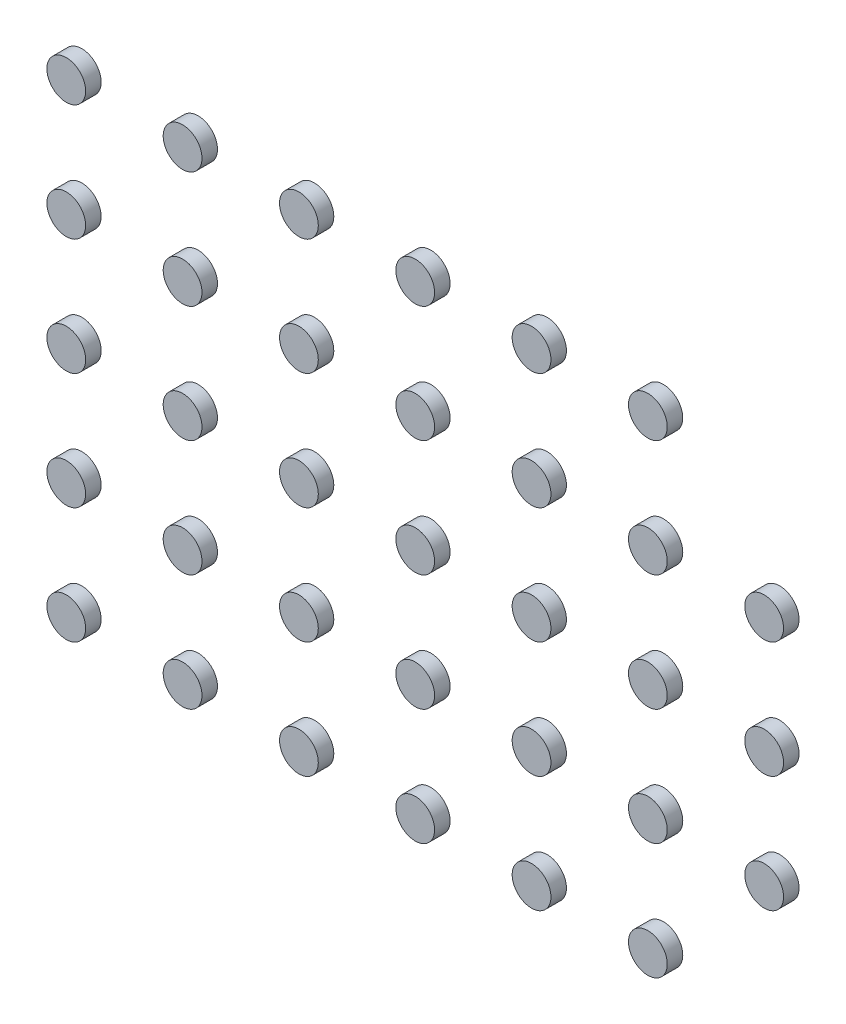
from build123d import *

# Parameters (mm, degrees)
SKETCH_1_R         = 0.5
EXTRUDE_1_DEPTH    = 0.4
EXTRUDE_1_2_DEPTH  = 0.4
EXTRUDE_1_3_DEPTH  = 0.4
EXTRUDE_1_4_DEPTH  = 0.4
EXTRUDE_1_5_DEPTH  = 0.4
EXTRUDE_1_6_DEPTH  = 0.4
EXTRUDE_1_7_DEPTH  = 0.4
EXTRUDE_1_8_DEPTH  = 0.4
EXTRUDE_1_9_DEPTH  = 0.4
EXTRUDE_1_10_DEPTH = 0.4
EXTRUDE_1_11_DEPTH = 0.4
EXTRUDE_1_12_DEPTH = 0.4
EXTRUDE_1_13_DEPTH = 0.4
EXTRUDE_1_14_DEPTH = 0.4
EXTRUDE_1_15_DEPTH = 0.4
EXTRUDE_1_16_DEPTH = 0.4
EXTRUDE_1_17_DEPTH = 0.4
EXTRUDE_1_18_DEPTH = 0.4
EXTRUDE_1_19_DEPTH = 0.4
EXTRUDE_1_20_DEPTH = 0.4
EXTRUDE_1_21_DEPTH = 0.4
EXTRUDE_1_22_DEPTH = 0.4
EXTRUDE_1_23_DEPTH = 0.4
EXTRUDE_1_24_DEPTH = 0.4
EXTRUDE_1_25_DEPTH = 0.4
EXTRUDE_1_26_DEPTH = 0.4
EXTRUDE_1_27_DEPTH = 0.4
EXTRUDE_1_28_DEPTH = 0.4
EXTRUDE_1_29_DEPTH = 0.4
EXTRUDE_1_30_DEPTH = 0.4
EXTRUDE_1_31_DEPTH = 0.4
EXTRUDE_1_32_DEPTH = 0.4
EXTRUDE_1_33_DEPTH = 0.4
EXTRUDE_1_34_DEPTH = 0.4
EXTRUDE_1_35_DEPTH = 0.4
EXTRUDE_1_36_DEPTH = 0.4
EXTRUDE_1_37_DEPTH = 0.4
EXTRUDE_1_38_DEPTH = 0.4
EXTRUDE_1_39_DEPTH = 0.4
EXTRUDE_1_40_DEPTH = 0.4
EXTRUDE_1_41_DEPTH = 0.4
EXTRUDE_1_42_DEPTH = 0.4


with BuildPart() as part:
    # 草图1 → 凸台-拉伸1 (new body)
    with BuildSketch(Plane.XY):
        with Locations((-4.5, 1.5)):
            Circle(SKETCH_1_R)
    extrude(amount=EXTRUDE_1_DEPTH)


with BuildPart() as body_2:
    # 草图1 → Extrude 1 2 (new body)
    with BuildSketch(Plane.XY):
        with Locations((-1.5, 1.5)):
            Circle(SKETCH_1_R)
    extrude(amount=EXTRUDE_1_2_DEPTH)


with BuildPart() as body_3:
    # 草图1 → Extrude 1 3 (new body)
    with BuildSketch(Plane.XY):
        with Locations((1.5, 1.5)):
            Circle(SKETCH_1_R)
    extrude(amount=EXTRUDE_1_3_DEPTH)


with BuildPart() as body_4:
    # 草图1 → Extrude 1 4 (new body)
    with BuildSketch(Plane.XY):
        with Locations((4.5, 1.5)):
            Circle(SKETCH_1_R)
    extrude(amount=EXTRUDE_1_4_DEPTH)


with BuildPart() as body_5:
    # 草图1 → Extrude 1 5 (new body)
    with BuildSketch(Plane.XY):
        with Locations((7.5, 1.5)):
            Circle(SKETCH_1_R)
    extrude(amount=EXTRUDE_1_5_DEPTH)


with BuildPart() as body_6:
    # 草图1 → Extrude 1 6 (new body)
    with BuildSketch(Plane.XY):
        with Locations((10.5, 1.5)):
            Circle(SKETCH_1_R)
    extrude(amount=EXTRUDE_1_6_DEPTH)


with BuildPart() as body_7:
    # 草图1 → Extrude 1 7 (new body)
    with BuildSketch(Plane.XY):
        with Locations((10.5, -1.5)):
            Circle(SKETCH_1_R)
    extrude(amount=EXTRUDE_1_7_DEPTH)


with BuildPart() as body_8:
    # 草图1 → Extrude 1 8 (new body)
    with BuildSketch(Plane.XY):
        with Locations((7.5, -1.5)):
            Circle(SKETCH_1_R)
    extrude(amount=EXTRUDE_1_8_DEPTH)


with BuildPart() as body_9:
    # 草图1 → Extrude 1 9 (new body)
    with BuildSketch(Plane.XY):
        with Locations((-10.5, 7.5)):
            Circle(SKETCH_1_R)
    extrude(amount=EXTRUDE_1_9_DEPTH)


with BuildPart() as body_10:
    # 草图1 → Extrude 1 10 (new body)
    with BuildSketch(Plane.XY):
        with Locations((-1.5, 7.5)):
            Circle(SKETCH_1_R)
    extrude(amount=EXTRUDE_1_10_DEPTH)


with BuildPart() as body_11:
    # 草图1 → Extrude 1 11 (new body)
    with BuildSketch(Plane.XY):
        with Locations((1.5, 7.5)):
            Circle(SKETCH_1_R)
    extrude(amount=EXTRUDE_1_11_DEPTH)


with BuildPart() as body_12:
    # 草图1 → Extrude 1 12 (new body)
    with BuildSketch(Plane.XY):
        with Locations((4.5, 7.5)):
            Circle(SKETCH_1_R)
    extrude(amount=EXTRUDE_1_12_DEPTH)


with BuildPart() as body_13:
    # 草图1 → Extrude 1 13 (new body)
    with BuildSketch(Plane.XY):
        with Locations((-10.5, 1.5)):
            Circle(SKETCH_1_R)
    extrude(amount=EXTRUDE_1_13_DEPTH)


with BuildPart() as body_14:
    # 草图1 → Extrude 1 14 (new body)
    with BuildSketch(Plane.XY):
        with Locations((-10.5, 4.5)):
            Circle(SKETCH_1_R)
    extrude(amount=EXTRUDE_1_14_DEPTH)


with BuildPart() as body_15:
    # 草图1 → Extrude 1 15 (new body)
    with BuildSketch(Plane.XY):
        with Locations((-10.5, -1.5)):
            Circle(SKETCH_1_R)
    extrude(amount=EXTRUDE_1_15_DEPTH)


with BuildPart() as body_16:
    # 草图1 → Extrude 1 16 (new body)
    with BuildSketch(Plane.XY):
        with Locations((-10.5, -4.5)):
            Circle(SKETCH_1_R)
    extrude(amount=EXTRUDE_1_16_DEPTH)


with BuildPart() as body_17:
    # 草图1 → Extrude 1 17 (new body)
    with BuildSketch(Plane.XY):
        with Locations((-10.5, -7.5)):
            Circle(SKETCH_1_R)
    extrude(amount=EXTRUDE_1_17_DEPTH)


with BuildPart() as body_18:
    # 草图1 → Extrude 1 18 (new body)
    with BuildSketch(Plane.XY):
        with Locations((-7.5, -7.5)):
            Circle(SKETCH_1_R)
    extrude(amount=EXTRUDE_1_18_DEPTH)


with BuildPart() as body_19:
    # 草图1 → Extrude 1 19 (new body)
    with BuildSketch(Plane.XY):
        with Locations((-7.5, -4.5)):
            Circle(SKETCH_1_R)
    extrude(amount=EXTRUDE_1_19_DEPTH)


with BuildPart() as body_20:
    # 草图1 → Extrude 1 20 (new body)
    with BuildSketch(Plane.XY):
        with Locations((-7.5, -1.5)):
            Circle(SKETCH_1_R)
    extrude(amount=EXTRUDE_1_20_DEPTH)


with BuildPart() as body_21:
    # 草图1 → Extrude 1 21 (new body)
    with BuildSketch(Plane.XY):
        with Locations((-7.5, 1.5)):
            Circle(SKETCH_1_R)
    extrude(amount=EXTRUDE_1_21_DEPTH)


with BuildPart() as body_22:
    # 草图1 → Extrude 1 22 (new body)
    with BuildSketch(Plane.XY):
        with Locations((-7.5, 4.5)):
            Circle(SKETCH_1_R)
    extrude(amount=EXTRUDE_1_22_DEPTH)


with BuildPart() as body_23:
    # 草图1 → Extrude 1 23 (new body)
    with BuildSketch(Plane.XY):
        with Locations((-4.5, 4.5)):
            Circle(SKETCH_1_R)
    extrude(amount=EXTRUDE_1_23_DEPTH)


with BuildPart() as body_24:
    # 草图1 → Extrude 1 24 (new body)
    with BuildSketch(Plane.XY):
        with Locations((-1.5, 4.5)):
            Circle(SKETCH_1_R)
    extrude(amount=EXTRUDE_1_24_DEPTH)


with BuildPart() as body_25:
    # 草图1 → Extrude 1 25 (new body)
    with BuildSketch(Plane.XY):
        with Locations((1.5, 4.5)):
            Circle(SKETCH_1_R)
    extrude(amount=EXTRUDE_1_25_DEPTH)


with BuildPart() as body_26:
    # 草图1 → Extrude 1 26 (new body)
    with BuildSketch(Plane.XY):
        with Locations((7.5, 4.5)):
            Circle(SKETCH_1_R)
    extrude(amount=EXTRUDE_1_26_DEPTH)


with BuildPart() as body_27:
    # 草图1 → Extrude 1 27 (new body)
    with BuildSketch(Plane.XY):
        with Locations((1.5, -1.5)):
            Circle(SKETCH_1_R)
    extrude(amount=EXTRUDE_1_27_DEPTH)


with BuildPart() as body_28:
    # 草图1 → Extrude 1 28 (new body)
    with BuildSketch(Plane.XY):
        with Locations((-1.5, -1.5)):
            Circle(SKETCH_1_R)
    extrude(amount=EXTRUDE_1_28_DEPTH)


with BuildPart() as body_29:
    # 草图1 → Extrude 1 29 (new body)
    with BuildSketch(Plane.XY):
        with Locations((-4.5, -1.5)):
            Circle(SKETCH_1_R)
    extrude(amount=EXTRUDE_1_29_DEPTH)


with BuildPart() as body_30:
    # 草图1 → Extrude 1 30 (new body)
    with BuildSketch(Plane.XY):
        with Locations((-4.5, -4.5)):
            Circle(SKETCH_1_R)
    extrude(amount=EXTRUDE_1_30_DEPTH)


with BuildPart() as body_31:
    # 草图1 → Extrude 1 31 (new body)
    with BuildSketch(Plane.XY):
        with Locations((-1.5, -4.5)):
            Circle(SKETCH_1_R)
    extrude(amount=EXTRUDE_1_31_DEPTH)


with BuildPart() as body_32:
    # 草图1 → Extrude 1 32 (new body)
    with BuildSketch(Plane.XY):
        with Locations((-4.5, -7.5)):
            Circle(SKETCH_1_R)
    extrude(amount=EXTRUDE_1_32_DEPTH)


with BuildPart() as body_33:
    # 草图1 → Extrude 1 33 (new body)
    with BuildSketch(Plane.XY):
        with Locations((-1.5, -7.5)):
            Circle(SKETCH_1_R)
    extrude(amount=EXTRUDE_1_33_DEPTH)


with BuildPart() as body_34:
    # 草图1 → Extrude 1 34 (new body)
    with BuildSketch(Plane.XY):
        with Locations((1.5, -7.5)):
            Circle(SKETCH_1_R)
    extrude(amount=EXTRUDE_1_34_DEPTH)


with BuildPart() as body_35:
    # 草图1 → Extrude 1 35 (new body)
    with BuildSketch(Plane.XY):
        with Locations((4.5, -7.5)):
            Circle(SKETCH_1_R)
    extrude(amount=EXTRUDE_1_35_DEPTH)


with BuildPart() as body_36:
    # 草图1 → Extrude 1 36 (new body)
    with BuildSketch(Plane.XY):
        with Locations((4.5, -4.5)):
            Circle(SKETCH_1_R)
    extrude(amount=EXTRUDE_1_36_DEPTH)


with BuildPart() as body_37:
    # 草图1 → Extrude 1 37 (new body)
    with BuildSketch(Plane.XY):
        with Locations((7.5, -4.5)):
            Circle(SKETCH_1_R)
    extrude(amount=EXTRUDE_1_37_DEPTH)


with BuildPart() as body_38:
    # 草图1 → Extrude 1 38 (new body)
    with BuildSketch(Plane.XY):
        with Locations((4.5, -1.5)):
            Circle(SKETCH_1_R)
    extrude(amount=EXTRUDE_1_38_DEPTH)


with BuildPart() as body_39:
    # 草图1 → Extrude 1 39 (new body)
    with BuildSketch(Plane.XY):
        with Locations((-7.5, 7.5)):
            Circle(SKETCH_1_R)
    extrude(amount=EXTRUDE_1_39_DEPTH)


with BuildPart() as body_40:
    # 草图1 → Extrude 1 40 (new body)
    with BuildSketch(Plane.XY):
        with Locations((-4.5, 7.5)):
            Circle(SKETCH_1_R)
    extrude(amount=EXTRUDE_1_40_DEPTH)


with BuildPart() as body_41:
    # 草图1 → Extrude 1 41 (new body)
    with BuildSketch(Plane.XY):
        with Locations((4.5, 4.5)):
            Circle(SKETCH_1_R)
    extrude(amount=EXTRUDE_1_41_DEPTH)


with BuildPart() as body_42:
    # 草图1 → Extrude 1 42 (new body)
    with BuildSketch(Plane.XY):
        with Locations((1.5, -4.5)):
            Circle(SKETCH_1_R)
    extrude(amount=EXTRUDE_1_42_DEPTH)


solid = Compound([part.part, body_2.part, body_3.part, body_4.part, body_5.part, body_8.part, body_9.part, body_10.part, body_11.part, body_12.part, body_13.part, body_14.part, body_15.part, body_16.part, body_19.part, body_20.part, body_21.part, body_22.part, body_23.part, body_24.part, body_25.part, body_26.part, body_27.part, body_28.part, body_29.part, body_30.part, body_31.part, body_36.part, body_38.part, body_39.part, body_40.part, body_41.part, body_42.part])
